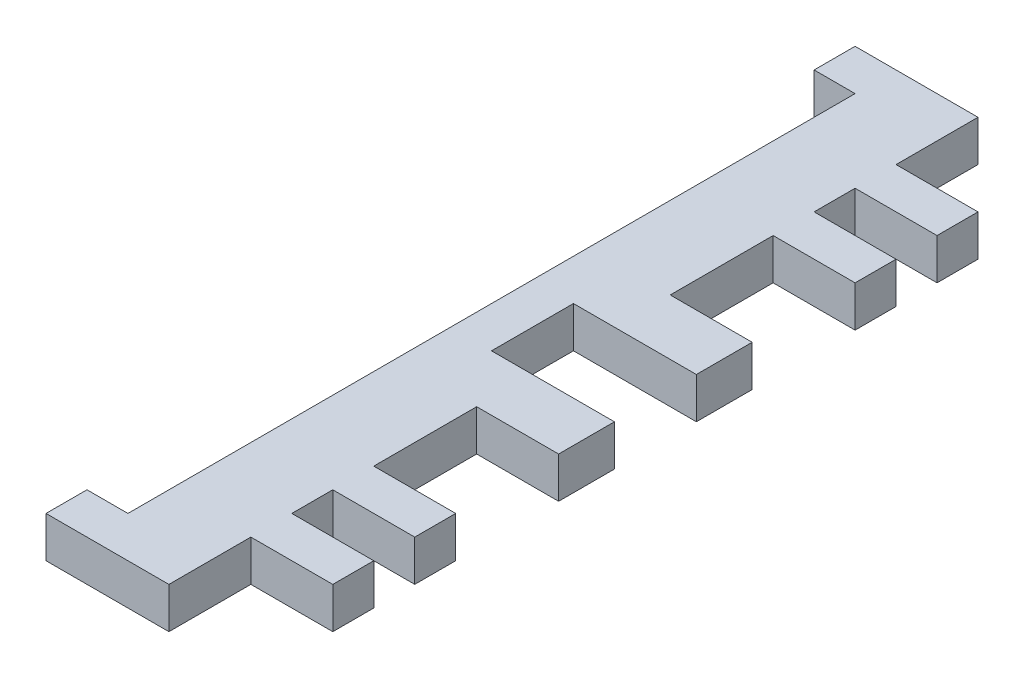
from build123d import *

# Parameters (mm, degrees)
SKETCH1_W           = 25.4
SKETCH1_H           = 125.4
BOSS_EXTRUDE1_DEPTH = 6.35
SKETCH2_W           = 112.7
SKETCH2_H           = 6.35
CUT_EXTRUDE1_DEPTH  = 12.7
SKETCH3_W           = 12.7
SKETCH3_H           = 6.35
CUT_EXTRUDE2_DEPTH  = 6.35
SKETCH4_W           = 8.65
SKETCH4_H           = 6.35
BOSS_EXTRUDE2_DEPTH = 12.7
SKETCH5_W           = 6.35
SKETCH5_H           = 6.35
BOSS_EXTRUDE3_DEPTH = 12.7
SKETCH6_W           = 6.35
SKETCH6_H           = 6.35
BOSS_EXTRUDE4_DEPTH = 12.7
SKETCH10_W          = 6.35
SKETCH10_H          = 6.35
CUT_EXTRUDE3_DEPTH  = 7.35


with BuildPart() as part:
    # Sketch1 → Boss-Extrude1 (new body)
    with BuildSketch(Plane(origin=(0, 0, 0), x_dir=(1, 0, 0), z_dir=(0, 1, 0))):
        Rectangle(SKETCH1_W, SKETCH1_H)
    extrude(amount=BOSS_EXTRUDE1_DEPTH)

    # Sketch2 → Cut-Extrude1 (cut)
    with BuildSketch(Plane.ZY.offset(12.7)):
        with Locations((0, 3.175)):
            Rectangle(SKETCH2_W, SKETCH2_H)
    extrude(amount=-CUT_EXTRUDE1_DEPTH, mode=Mode.SUBTRACT)

    # Sketch3 → Cut-Extrude2 (cut)
    with BuildSketch(Plane(origin=(12.7, 0, 0), x_dir=(0, 0, -1), z_dir=(1, 0, 0))):
        with Locations((0, 3.175)):
            Rectangle(SKETCH3_W, SKETCH3_H)
    extrude(amount=-CUT_EXTRUDE2_DEPTH, mode=Mode.SUBTRACT)

    # Sketch4 → Boss-Extrude2 (add)
    with BuildSketch(Plane(origin=(12.7, 0, 0), x_dir=(0, 0, -1), z_dir=(1, 0, 0))):
        with Locations((-10.675, 3.175)):
            Rectangle(SKETCH4_W, SKETCH4_H)
    boss_extrude2 = extrude(amount=BOSS_EXTRUDE2_DEPTH)

    # Mirror1: Boss-Extrude2 across plane
    add(boss_extrude2.mirror(Plane.XY))

    # Sketch5 → Boss-Extrude3 (add)
    with BuildSketch(Plane(origin=(12.7, 0, 0), x_dir=(0, 0, -1), z_dir=(1, 0, 0))):
        with Locations((46.825, 3.175)):
            Rectangle(SKETCH5_W, SKETCH5_H)
    boss_extrude3 = extrude(amount=BOSS_EXTRUDE3_DEPTH)

    # Sketch6 → Boss-Extrude4 (add)
    with BuildSketch(Plane(origin=(12.7, 0, 0), x_dir=(0, 0, -1), z_dir=(1, 0, 0))):
        with Locations((34.125, 3.175)):
            Rectangle(SKETCH6_W, SKETCH6_H)
    boss_extrude4 = extrude(amount=BOSS_EXTRUDE4_DEPTH)

    # Mirror2: Boss-Extrude3, Boss-Extrude4 across plane
    add(boss_extrude3.mirror(Plane.XY))
    add(boss_extrude4.mirror(Plane.XY))

    # Sketch10 → Cut-Extrude3 (cut, through all)
    with BuildSketch(Plane(origin=(0, 6.35, 0), x_dir=(1, 0, 0), z_dir=(0, 1, 0))):
        with Locations((-9.525, 59.525)):
            Rectangle(SKETCH10_W, SKETCH10_H)
    cut_extrude3 = extrude(amount=-CUT_EXTRUDE3_DEPTH, mode=Mode.SUBTRACT)

    # Mirror3: Cut-Extrude3 across plane
    add(cut_extrude3.mirror(Plane.XY), mode=Mode.SUBTRACT)


solid = part.part
